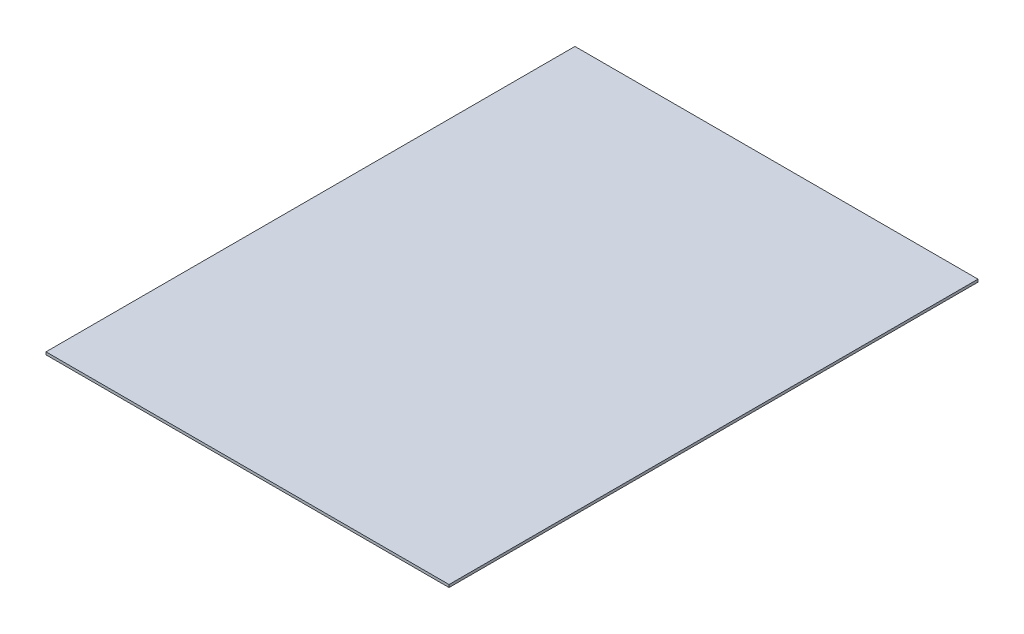
from build123d import *

# Parameters (mm, degrees)
SKETCH1_W           = 1524
SKETCH1_H           = 2000
BOSS_EXTRUDE1_DEPTH = 10


with BuildPart() as part:
    # Sketch1 → Boss-Extrude1 (new body)
    with BuildSketch(Plane(origin=(0, 0, 0), x_dir=(1, 0, 0), z_dir=(0, 1, 0))):
        Rectangle(SKETCH1_W, SKETCH1_H)
    extrude(amount=BOSS_EXTRUDE1_DEPTH)


solid = part.part
